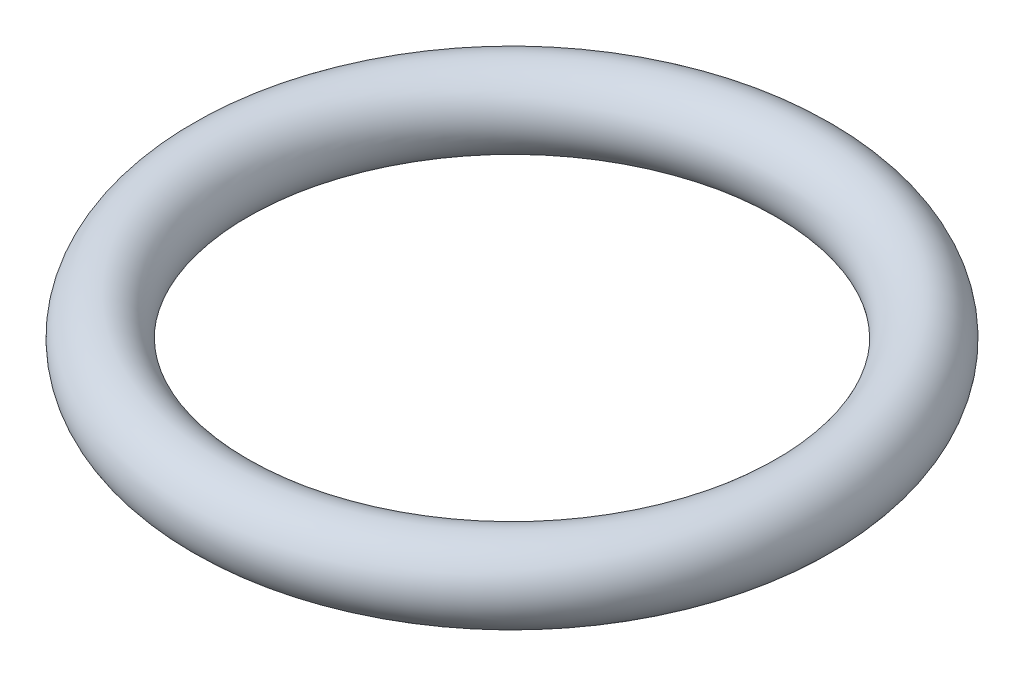
from build123d import *

# Parameters (mm, degrees)
SKETCH2_R = 2.5


with BuildPart() as part:
    # Sketch2 → Revolve1 (revolve)
    with BuildSketch(Plane.XY):
        with Locations((19, 0)):
            Circle(SKETCH2_R)
    revolve(axis=Axis((0, 7.016372871, 0), (0, -1, 0)))


solid = part.part
